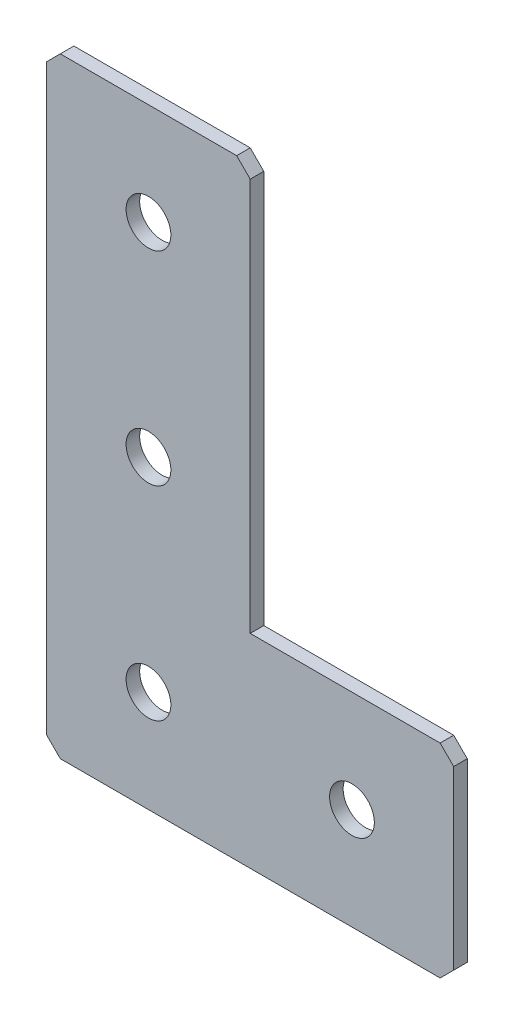
from build123d import *

# Parameters (mm, degrees)
EXTRUDE_1_DEPTH   = 2
HOLE_WIZARD_M61_D = 6.6
CHAMFER_1_SIZE    = 2


with BuildPart() as part:
    # Эскиз1 → Бобышка-Вытянуть1 (new body)
    with BuildSketch(Plane(origin=(0, 0, 0), x_dir=(1, 0, 0), z_dir=(0, 0, -1))):
        Polygon((0, 0), (0, 90), (60, 90), (60, 60), (30, 60), (30, 0), align=None)
    extrude(amount=EXTRUDE_1_DEPTH)

    # Отверстие с зазором M61 (through all)
    with Locations(Plane(origin=(0, 0, -2), x_dir=(1, 0, 0), z_dir=(0, 0, -1))):
        with Locations((45, 75), (15, 75), (15, 45), (15, 15)):
            Hole(HOLE_WIZARD_M61_D / 2)

    # Фаска1
    chamfer_1_edges = [part.edges().sort_by_distance(p)[0] for p in [
        (0, 0, -1),
        (0, -90, -1),
        (60, -90, -1),
        (60, -60, -1),
        (30, 0, -1),
    ]]
    chamfer(chamfer_1_edges, length=CHAMFER_1_SIZE)


solid = part.part
